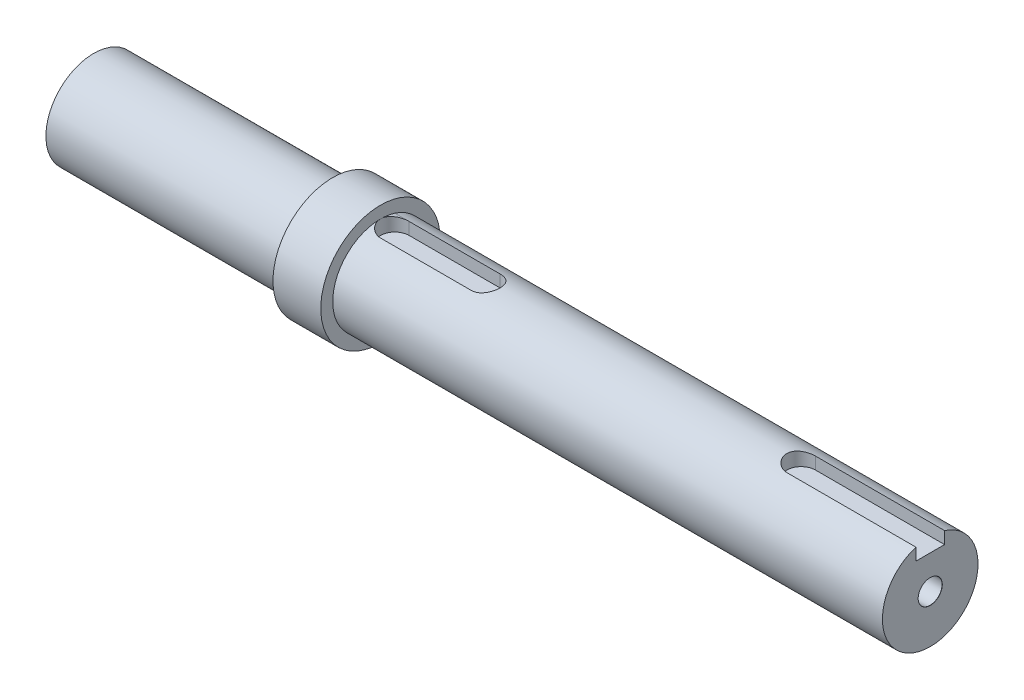
from build123d import *

# Parameters (mm, degrees)
F_5_0MM_DOWEL_HOLE1_D           = 5
F_5_0MM_DOWEL_HOLE1_DEPTH       = 10
F_5_0MM_DOWEL_HOLE1_CSINK_D     = 5.05
F_5_0MM_DOWEL_HOLE1_CSINK_ANGLE = 90
F_5_0MM_DOWEL_HOLE1_TIP         = 1.502151548
CUT_EXTRUDE1_DEPTH              = 3


with BuildPart() as part:
    # Sketch1 → Revolve1 (revolve)
    with BuildSketch(Plane(origin=(0, 0, 0), x_dir=(1, 0, 0), z_dir=(0, 1, 0))):
        Polygon((0, 0), (0, 10), (50, 10), (50, 12.5), (60, 12.5), (60, 10), (175, 10), (175, 0), align=None)
    revolve(axis=Axis((175, 0, 0), (-1, 0, 0)))

    # Ø5.0mm Dowel Hole1
    with Locations(Plane(origin=(0, 0, 0), x_dir=(0, 0, -1), z_dir=(-1, 0, 0))):
        with Locations((0, 0)):
            CounterSinkHole(F_5_0MM_DOWEL_HOLE1_D / 2, F_5_0MM_DOWEL_HOLE1_CSINK_D / 2, depth=F_5_0MM_DOWEL_HOLE1_DEPTH, counter_sink_angle=F_5_0MM_DOWEL_HOLE1_CSINK_ANGLE)
            with Locations((0, 0, -(F_5_0MM_DOWEL_HOLE1_DEPTH + F_5_0MM_DOWEL_HOLE1_TIP / 2))):  # 118° drill point
                Cone(0, F_5_0MM_DOWEL_HOLE1_D / 2, F_5_0MM_DOWEL_HOLE1_TIP, mode=Mode.SUBTRACT)

    # Sketch9 → Ø5.0mm Dowel Hole2 (revolve, cut)
    with BuildSketch(Plane(origin=(175, 0, 0), x_dir=(0, 0, -1), z_dir=(0, 1, 0))):
        Polygon((0, 0), (0, 11.502151548), (2.5, 10), (2.5, 0.025), (2.525, 0), align=None)
    revolve(axis=Axis((181.35, 0, 0), (-1, 0, 0)), mode=Mode.SUBTRACT)

    # Sketch10 → Cut-Extrude1 (cut)
    with BuildSketch(Plane(origin=(0, 10, 0), x_dir=(1, 0, 0), z_dir=(0, 1, 0))):
        with BuildLine():
            Line((63, 3), (82, 3))
            ThreePointArc((82, 3), (85, 0), (82, -3))
            Line((82, -3), (63, -3))
            ThreePointArc((63, -3), (60, 0), (63, 3))
        make_face()
        with BuildLine():
            Line((175, -3), (148, -3))
            ThreePointArc((148, -3), (145, 0), (148, 3))
            Line((148, 3), (175, 3))
            ThreePointArc((175, 3), (178, 0), (175, -3))
        make_face()
    extrude(amount=-CUT_EXTRUDE1_DEPTH, mode=Mode.SUBTRACT)


solid = part.part
